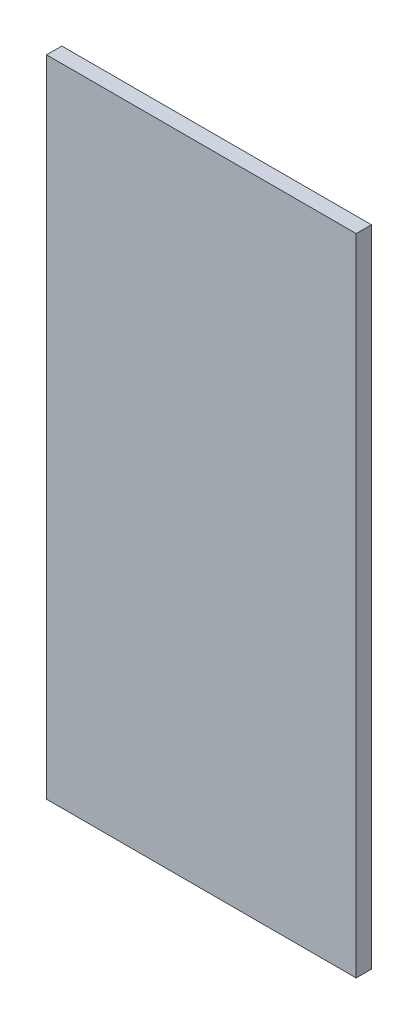
from build123d import *

# Parameters (mm, degrees)
SKETCH1_W           = 365
SKETCH1_H           = 760
BOSS_EXTRUDE1_DEPTH = 18


with BuildPart() as part:
    # Sketch1 → Boss-Extrude1 (new body)
    with BuildSketch(Plane.XY):
        Rectangle(SKETCH1_W, SKETCH1_H)
    extrude(amount=BOSS_EXTRUDE1_DEPTH)


solid = part.part
